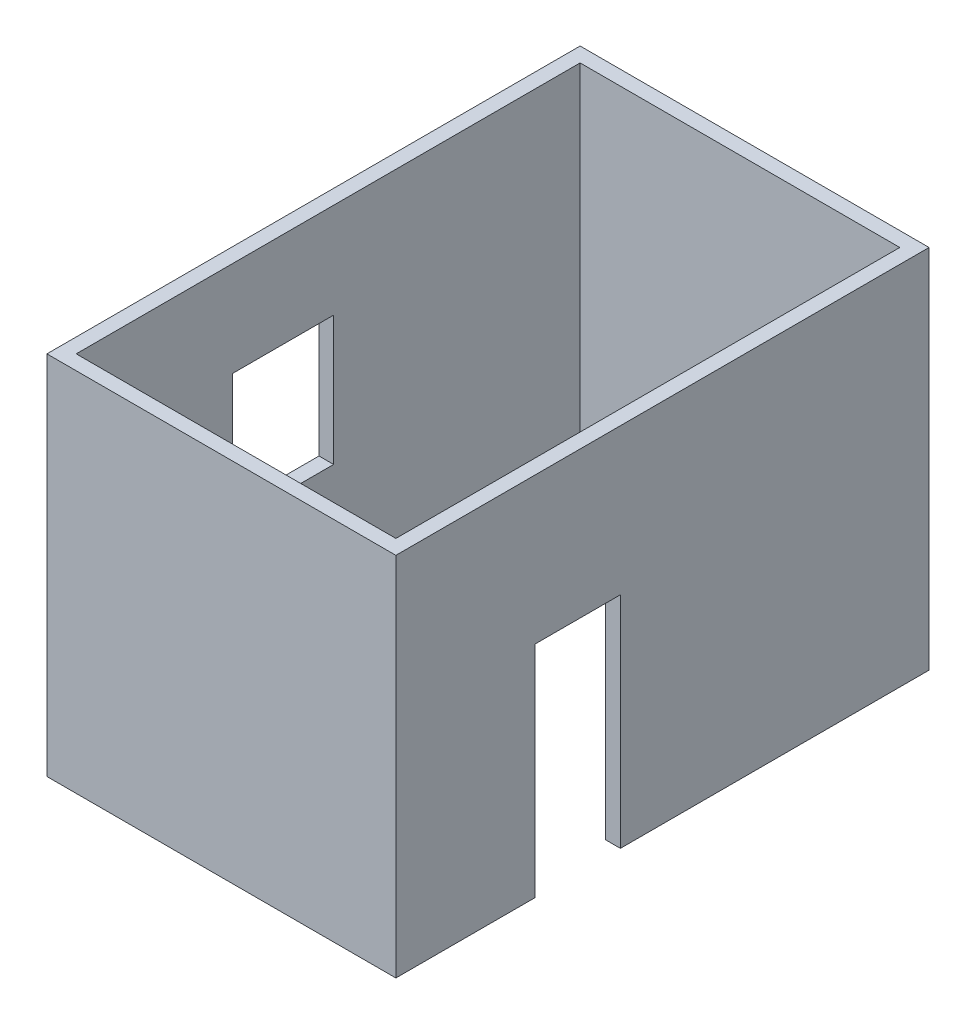
from build123d import *

# Parameters (mm, degrees)
SKETCH_1_W          = 2860
SKETCH_1_H          = 4370
SKETCH_1_W_2        = 2620
SKETCH_1_H_2        = 4130
EXTRUDE_1_DEPTH     = 3000
CUT_EXTRUDE_1_REACH = 2862
SKETCH_2_W          = 700
SKETCH_2_H          = 1800
CUT_EXTRUDE_2_REACH = 122
SKETCH_3_W          = 830
SKETCH_3_H          = 1060


with BuildPart() as part:
    # 草图1 → 拉伸-薄壁1 (new body)
    with BuildSketch(Plane(origin=(0, 0, 0), x_dir=(1, 0, 0), z_dir=(0, 1, 0))):
        with Locations((-1310, 2065)):
            Rectangle(SKETCH_1_W, SKETCH_1_H)
        with Locations((-1310, 2065)):
            Rectangle(SKETCH_1_W_2, SKETCH_1_H_2, mode=Mode.SUBTRACT)
    extrude(amount=EXTRUDE_1_DEPTH)

    # 草图2 → 切除-拉伸1 (cut, up to next)
    with BuildSketch(Plane(origin=(120, 0, 0), x_dir=(0, 0, -1), z_dir=(1, 0, 0)), mode=Mode.PRIVATE) as cut_extrude_1_sk1:
        with Locations((1370, 900)):
            Rectangle(SKETCH_2_W, SKETCH_2_H)
    cut_extrude_1_tool1 = extrude(cut_extrude_1_sk1.sketch, amount=-CUT_EXTRUDE_1_REACH, mode=Mode.PRIVATE) & part.part
    add(cut_extrude_1_tool1.solids().sort_by_distance((120, 900, -1370))[0], mode=Mode.SUBTRACT)

    # 草图3 → 切除-拉伸2 (cut, up to next)
    with BuildSketch(Plane(origin=(-2620, 0, 0), x_dir=(0, 0, -1), z_dir=(1, 0, 0)), mode=Mode.PRIVATE) as cut_extrude_2_sk1:
        with Locations((1695, 1690)):
            Rectangle(SKETCH_3_W, SKETCH_3_H)
    cut_extrude_2_tool1 = extrude(cut_extrude_2_sk1.sketch, amount=-CUT_EXTRUDE_2_REACH, mode=Mode.PRIVATE) & part.part
    add(cut_extrude_2_tool1.solids().sort_by_distance((-2620, 1690, -1695))[0], mode=Mode.SUBTRACT)


solid = part.part
